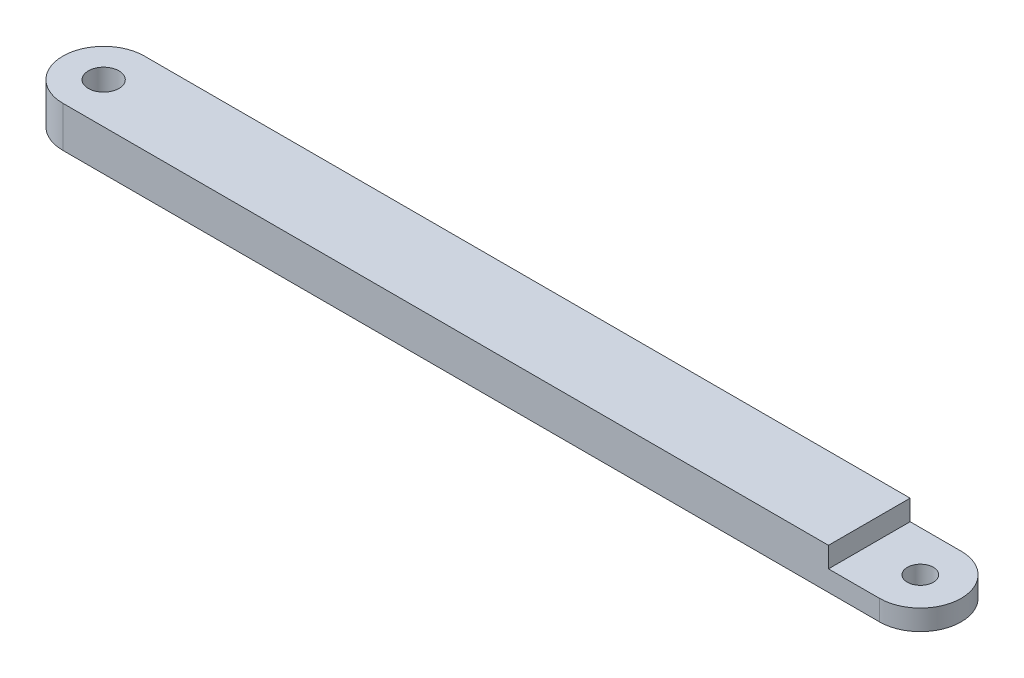
from build123d import *

# Parameters (mm, degrees)
BOSS_EXTRUDE1_DEPTH            = 6.35
F_3_16_0_1875_DIAMETER_HOLE1_D = 4.7625
F_21_0_159_DIAMETER_HOLE1_D    = 4.0386
SKETCH4_W                      = 15.875
SKETCH4_H                      = 12.7
CUT_EXTRUDE1_DEPTH             = 3.175


with BuildPart() as part:
    # Sketch1 → Boss-Extrude1 (new body)
    with BuildSketch(Plane(origin=(0, 0, 0), x_dir=(1, 0, 0), z_dir=(0, 1, 0))):
        with BuildLine():
            Line((-63.5, 6.35), (63.5, 6.35))
            ThreePointArc((63.5, 6.35), (69.85, 0), (63.5, -6.35))
            Line((63.5, -6.35), (-63.5, -6.35))
            ThreePointArc((-63.5, -6.35), (-69.85, 0), (-63.5, 6.35))
        make_face()
    extrude(amount=BOSS_EXTRUDE1_DEPTH)

    # 3/16 (0.1875) Diameter Hole1 (through all)
    with Locations(Plane(origin=(0, 6.35, 0), x_dir=(1, 0, 0), z_dir=(0, 1, 0))):
        with Locations((-63.5, 0)):
            Hole(F_3_16_0_1875_DIAMETER_HOLE1_D / 2)

    # #21 (0.159) Diameter Hole1 (through all)
    with Locations(Plane(origin=(0, 6.35, 0), x_dir=(1, 0, 0), z_dir=(0, 1, 0))):
        with Locations((63.5, 0)):
            Hole(F_21_0_159_DIAMETER_HOLE1_D / 2)

    # Sketch4 → Cut-Extrude1 (cut)
    with BuildSketch(Plane(origin=(0, 6.35, 0), x_dir=(1, 0, 0), z_dir=(0, 1, 0))):
        with Locations((63.5, 0)):
            Rectangle(SKETCH4_W, SKETCH4_H)
    extrude(amount=-CUT_EXTRUDE1_DEPTH, mode=Mode.SUBTRACT)


solid = part.part
